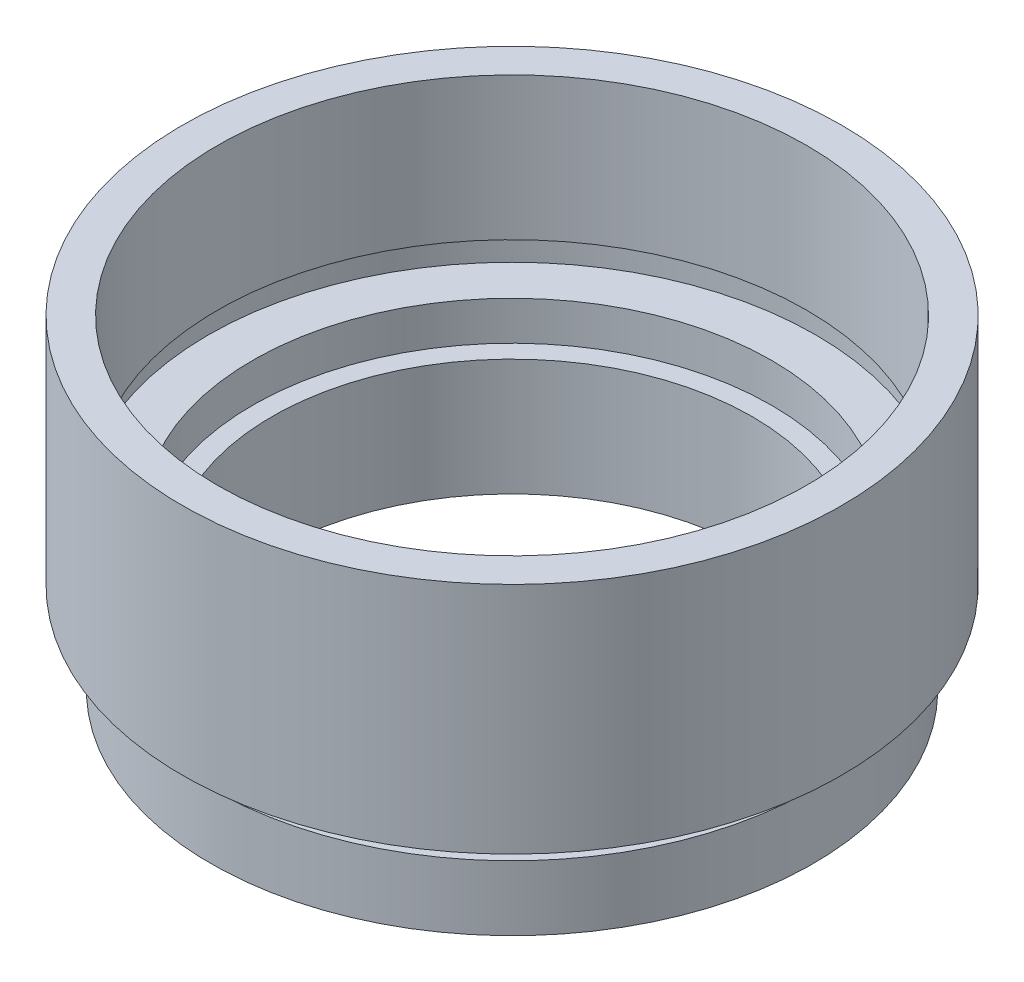
from build123d import *


with BuildPart() as part:
    # 草图1 → 旋转1 (revolve)
    with BuildSketch(Plane.XY, mode=Mode.PRIVATE) as revolve_1_sk:
        Polygon((9.25, 0), (11.6, 0), (11.6, 2.5), (11.1, 2.5), (11.1, 3.5), (12.7, 3.5), (12.7, 12.5), (11.35, 12.5), (11.35, 7), (11.7, 7), (11.7, 6), (10, 6), (10, 4.5), (9.25, 4.5), align=None)
    revolve(revolve_1_sk.sketch.rotate(Axis((0, 0, 0), (0, 1, 0)), 90), axis=Axis((0, 0, 0), (0, 1, 0)))  # turned: the seam where the file's is


solid = part.part
